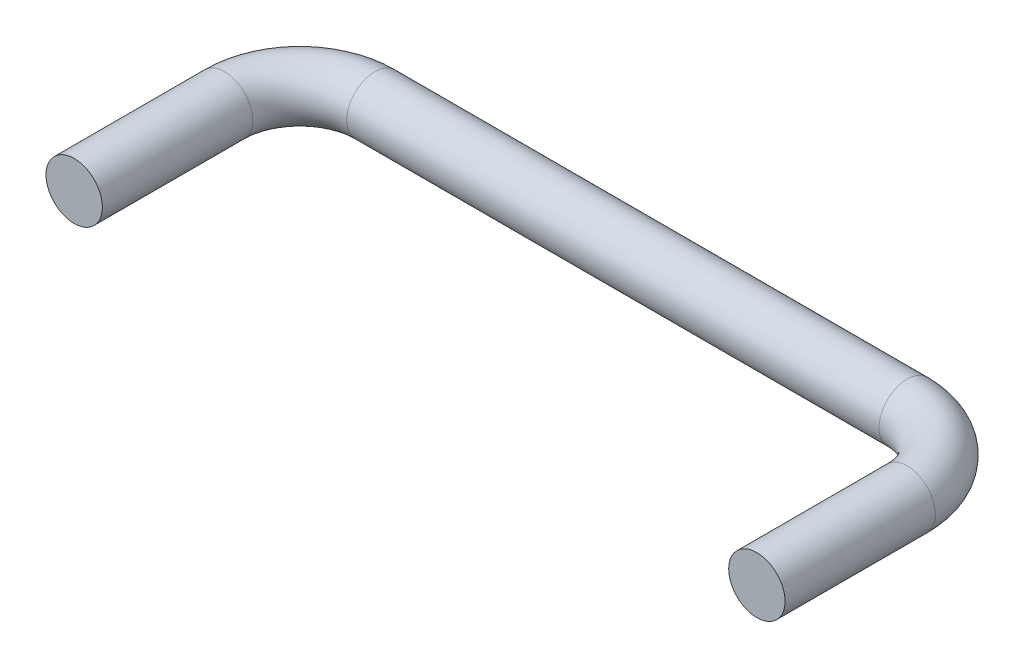
from build123d import *

# Parameters (mm, degrees)
CROQUIS2_R = 3.75


with BuildPart() as part:
    # Barrer1: sweep along a path in Croquis1
    with BuildLine(Plane(origin=(0, 0, 0), x_dir=(1, 0, 0), z_dir=(0, 1, 0))) as barrer1_path:
        Line((0, 0), (0, 20))
        ThreePointArc((0, 20), (2.928932188, 27.071067812), (10, 30))
        Line((10, 30), (80.824, 30))
        ThreePointArc((80.824, 30), (87.895067812, 27.071067812), (90.824, 20))
        Line((90.824, 20), (90.824, 0))
    # Croquis2 → Barrer1 (sweep)
    with BuildSketch(Plane.XY):
        Circle(CROQUIS2_R)
    sweep(path=barrer1_path.line)


solid = part.part
